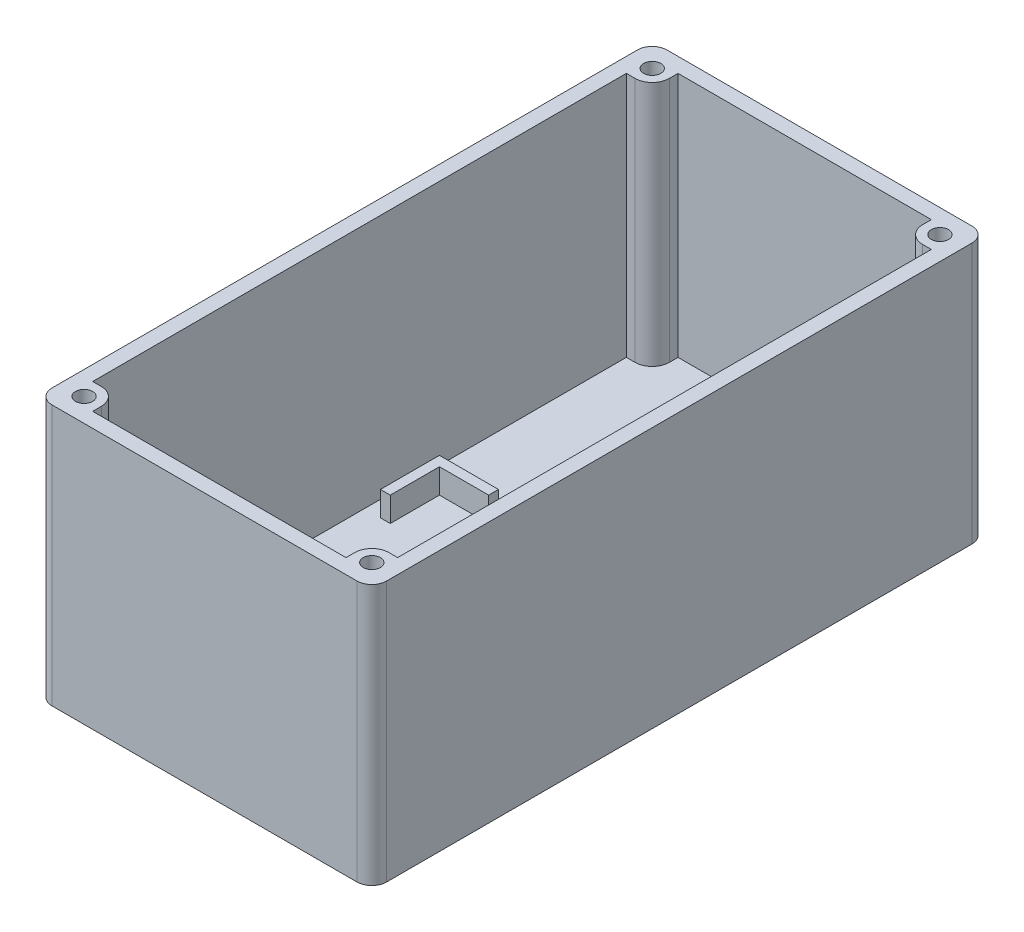
from build123d import *

# Parameters (mm, degrees)
SKETCH_1_W          = 68
SKETCH_1_H          = 125
EXTRUDE_1_DEPTH     = 3
SKETCH_3_W          = 68
SKETCH_3_H          = 125
SKETCH_3_W_2        = 62
SKETCH_3_H_2        = 119
EXTRUDE_1_2_DEPTH   = 50
FILLET_1_R          = 3
SKETCH_4_W          = 2
SKETCH_4_H          = 10
EXTRUDE_2_DEPTH     = 5
SKETCH_5_R          = 1.75
EXTRUDE_3_DEPTH     = 50
SKETCH_6_R          = 1.75
CUT_EXTRUDE_1_DEPTH = 54


with BuildPart() as part:
    # Эскиз1 → Extrude 1 (new body)
    with BuildSketch(Plane(origin=(0, 0, 0), x_dir=(1, 0, 0), z_dir=(0, 1, 0))):
        Rectangle(SKETCH_1_W, SKETCH_1_H)
    extrude(amount=EXTRUDE_1_DEPTH)

    # Эскиз3 → Extrude 1 2 (add)
    with BuildSketch(Plane(origin=(0, 3, 0), x_dir=(1, 0, 0), z_dir=(0, 1, 0))):
        Rectangle(SKETCH_3_W, SKETCH_3_H)
        Rectangle(SKETCH_3_W_2, SKETCH_3_H_2, mode=Mode.SUBTRACT)
    extrude(amount=EXTRUDE_1_2_DEPTH)

    # Скругление1
    fillet_1_edges = [part.edges().sort_by_distance(p)[0] for p in [
        (-34, 26.5, -62.5),
        (34, 26.5, -62.5),
        (34, 26.5, 62.5),
        (-34, 26.5, 62.5),
    ]]
    fillet(fillet_1_edges, radius=FILLET_1_R)

    # Эскиз4 → Бобышка-Вытянуть2 (add)
    with BuildSketch(Plane(origin=(0, 3, 0), x_dir=(1, 0, 0), z_dir=(0, 1, 0))):
        Polygon((15.75, 11), (25.75, 11), (25.75, 1), (27.75, 1), (27.75, 13), (15.75, 13), align=None)
        with Locations((26.75, -54.5)):
            Rectangle(SKETCH_4_W, SKETCH_4_H)
        with Locations((-26.75, -54.5)):
            Rectangle(SKETCH_4_W, SKETCH_4_H)
        Polygon((-27.75, 13), (-15.75, 13), (-15.75, 11), (-25.75, 11), (-25.75, 1), (-27.75, 1), align=None)
    extrude(amount=EXTRUDE_2_DEPTH)

    # Эскиз5 → Бобышка-Вытянуть3 (add)
    with BuildSketch(Plane(origin=(0, 53, 0), x_dir=(1, 0, 0), z_dir=(0, 1, 0))):
        with BuildLine():
            Line((-29.25, 54.25), (-32.75, 54.25))
            Line((-32.75, 54.25), (-32.75, 57.75))
            ThreePointArc((-32.75, 57.75), (-31.724873734, 60.224873734), (-29.25, 61.25))
            Line((-29.25, 61.25), (-25.75, 61.25))
            Line((-25.75, 61.25), (-25.75, 57.75))
            ThreePointArc((-25.75, 57.75), (-26.775126266, 55.275126266), (-29.25, 54.25))
        make_face()
        with Locations((-29.25, 57.75)):
            Circle(SKETCH_5_R, mode=Mode.SUBTRACT)
        with BuildLine():
            Line((25.75, 61.25), (29.25, 61.25))
            ThreePointArc((29.25, 61.25), (31.724873734, 60.224873734), (32.75, 57.75))
            Line((32.75, 57.75), (32.75, 54.25))
            Line((32.75, 54.25), (29.25, 54.25))
            ThreePointArc((29.25, 54.25), (26.775126266, 55.275126266), (25.75, 57.75))
            Line((25.75, 57.75), (25.75, 61.25))
        make_face()
        with Locations((29.25, 57.75)):
            Circle(SKETCH_5_R, mode=Mode.SUBTRACT)
        with BuildLine():
            Line((29.25, -54.25), (32.75, -54.25))
            Line((32.75, -54.25), (32.75, -57.75))
            ThreePointArc((32.75, -57.75), (31.724873734, -60.224873734), (29.25, -61.25))
            Line((29.25, -61.25), (25.75, -61.25))
            Line((25.75, -61.25), (25.75, -57.75))
            ThreePointArc((25.75, -57.75), (26.775126266, -55.275126266), (29.25, -54.25))
        make_face()
        with Locations((29.25, -57.75)):
            Circle(SKETCH_5_R, mode=Mode.SUBTRACT)
        with BuildLine():
            Line((-25.75, -61.25), (-29.25, -61.25))
            ThreePointArc((-29.25, -61.25), (-31.724873734, -60.224873734), (-32.75, -57.75))
            Line((-32.75, -57.75), (-32.75, -54.25))
            Line((-32.75, -54.25), (-29.25, -54.25))
            ThreePointArc((-29.25, -54.25), (-26.775126266, -55.275126266), (-25.75, -57.75))
            Line((-25.75, -57.75), (-25.75, -61.25))
        make_face()
        with Locations((-29.25, -57.75)):
            Circle(SKETCH_5_R, mode=Mode.SUBTRACT)
    extrude(amount=-EXTRUDE_3_DEPTH)

    # Эскиз6 → Вырез-Вытянуть1 (cut, through all)
    with BuildSketch(Plane(origin=(0, 53, 0), x_dir=(1, 0, 0), z_dir=(0, 1, 0))):
        with Locations((-29.25, 57.75)):
            Circle(SKETCH_6_R)
        with Locations((29.25, 57.75)):
            Circle(SKETCH_6_R)
        with Locations((29.25, -57.75)):
            Circle(SKETCH_6_R)
        with Locations((-29.25, -57.75)):
            Circle(SKETCH_6_R)
    extrude(amount=-CUT_EXTRUDE_1_DEPTH, mode=Mode.SUBTRACT)


solid = part.part
